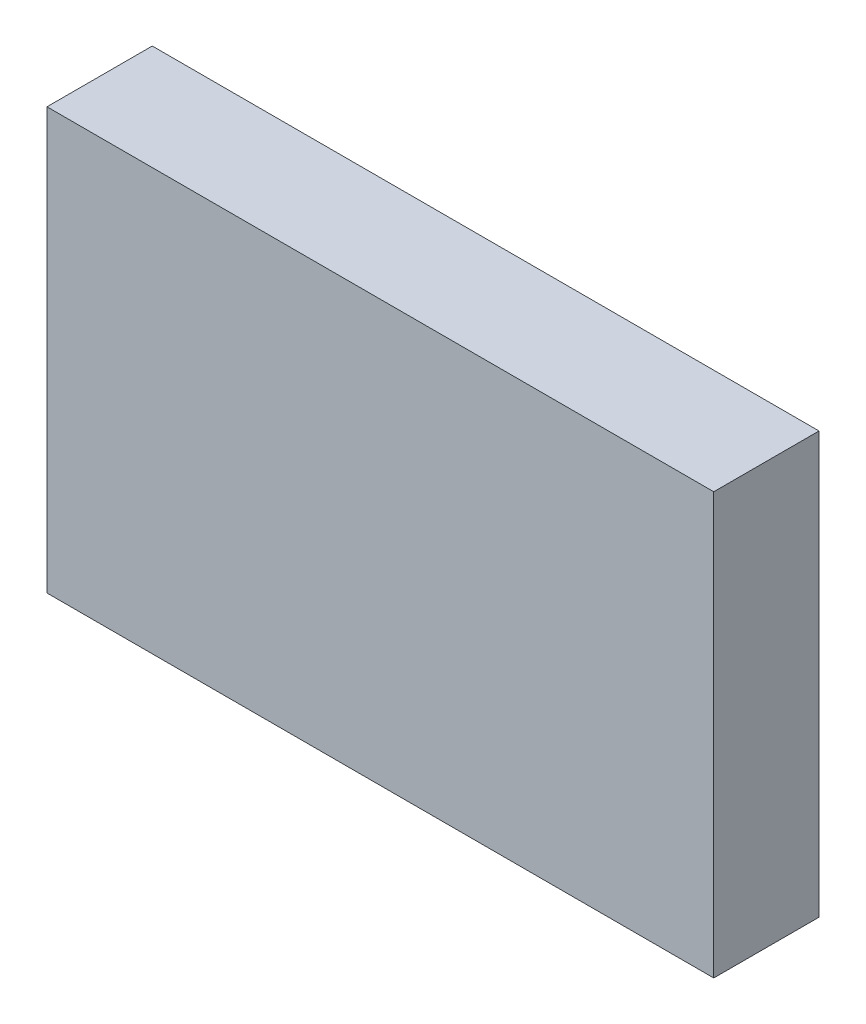
from build123d import *

# Parameters (mm, degrees)
CROQUIS1_W              = 95
CROQUIS1_H              = 60
SALIENTE_EXTRUIR1_DEPTH = 15


with BuildPart() as part:
    # Croquis1 → Saliente-Extruir1 (new body)
    with BuildSketch(Plane.XY):
        Rectangle(CROQUIS1_W, CROQUIS1_H)
    extrude(amount=SALIENTE_EXTRUIR1_DEPTH)


solid = part.part
